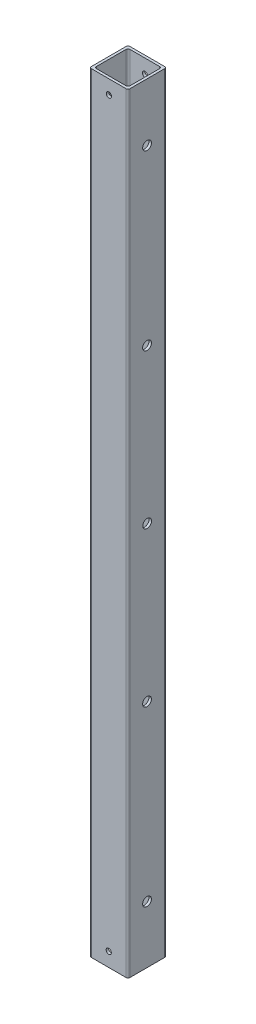
from build123d import *

# Parameters (mm, degrees)
SKETCH1_W                  = 25.4
SKETCH1_H                  = 25.4
SKETCH1_W_2                = 22.098
SKETCH1_H_2                = 22.098
BOSS_EXTRUDE1_DEPTH        = 508
FILLET1_R                  = 1.27
F_1_0_228_DIAMETER_HOLE2_D = 5.7912
F_8_32_TAPPED_HOLE1_D      = 3.4544


with BuildPart() as part:
    # Sketch1 → Boss-Extrude1 (new body)
    with BuildSketch(Plane(origin=(0, 0, 0), x_dir=(1, 0, 0), z_dir=(0, 1, 0))):
        Rectangle(SKETCH1_W, SKETCH1_H)
        Rectangle(SKETCH1_W_2, SKETCH1_H_2, mode=Mode.SUBTRACT)
    extrude(amount=BOSS_EXTRUDE1_DEPTH)

    # Fillet1
    fillet1_edges = [part.edges().sort_by_distance(p)[0] for p in [
        (-11.049, 254, 11.049),
        (11.049, 254, 11.049),
        (11.049, 254, -11.049),
        (-11.049, 254, -11.049),
        (12.7, 254, 12.7),
        (-12.7, 254, 12.7),
        (-12.7, 254, -12.7),
        (12.7, 254, -12.7),
    ]]
    fillet(fillet1_edges, radius=FILLET1_R)

    # #1 (0.228) Diameter Hole2 (through all)
    with Locations(Plane.ZY.offset(12.7)):
        with Locations((0.1524, 469.9), (0.1524, 355.6), (0.0762, 253.8476), (0.1524, 152.0952), (0.1524, 37.7952)):
            Hole(F_1_0_228_DIAMETER_HOLE2_D / 2)

    # #8-32 Tapped Hole1 (through all)
    with Locations(Plane.XY.offset(12.7)):
        with Locations((0, 9.271), (0.103095802, 498.729)):
            Hole(F_8_32_TAPPED_HOLE1_D / 2)


solid = part.part
